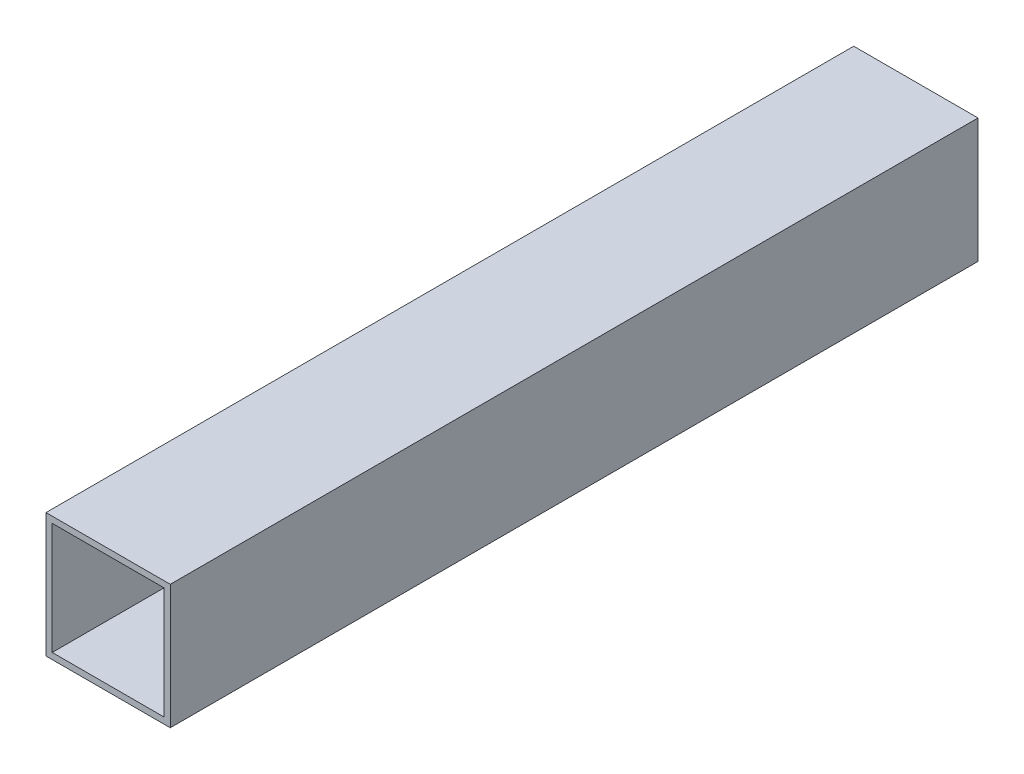
from build123d import *

# Parameters (mm, degrees)
SKETCH1_W           = 100
SKETCH1_H           = 100
SKETCH1_W_2         = 90
SKETCH1_H_2         = 90
BOSS_EXTRUDE1_DEPTH = 325


with BuildPart() as part:
    # Sketch1 → Boss-Extrude1 (new body, symmetric)
    with BuildSketch(Plane.XY):
        Rectangle(SKETCH1_W, SKETCH1_H)
        Rectangle(SKETCH1_W_2, SKETCH1_H_2, mode=Mode.SUBTRACT)
    extrude(amount=BOSS_EXTRUDE1_DEPTH, both=True)


solid = part.part
